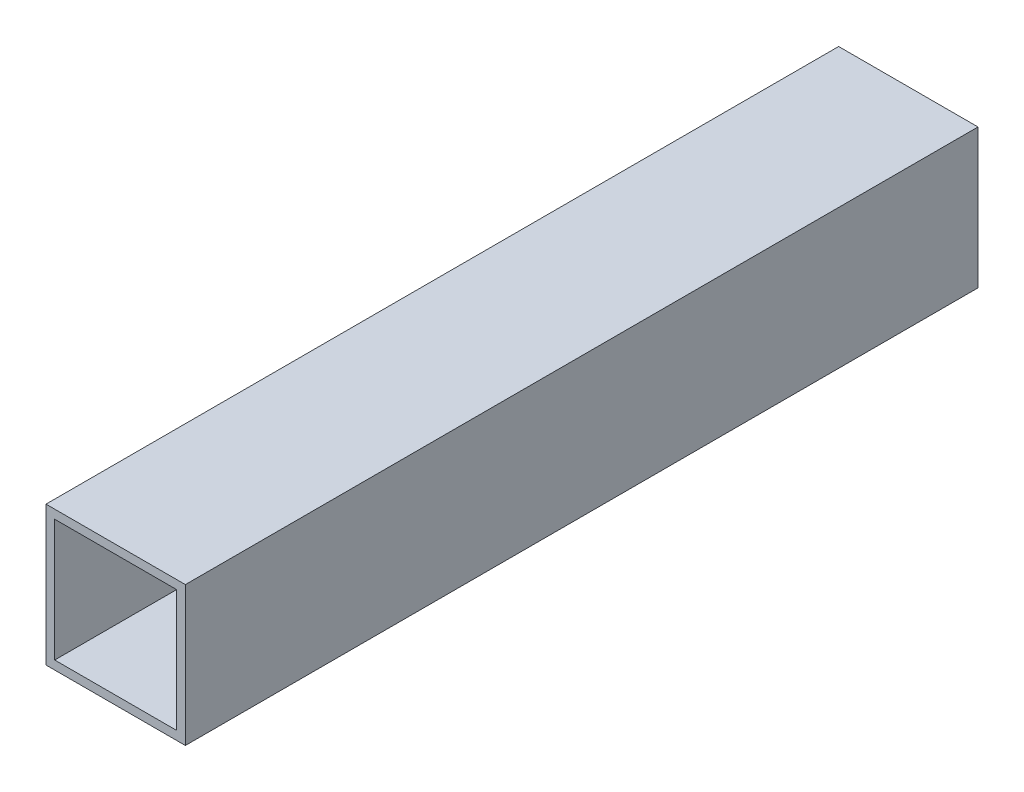
from build123d import *

# Parameters (mm, degrees)
SKETCH3_W                = 25.4
SKETCH3_H                = 25.4
SKETCH3_W_2              = 22.225
SKETCH3_H_2              = 22.225
BOSS_EXTRUDE1_DEPTH      = 76.2
BOSS_EXTRUDE1_DEPTH_BACK = 76.2
SKETCH4_W                = 25.4
SKETCH4_H                = 25.4
SKETCH4_W_2              = 22.225
SKETCH4_H_2              = 22.225
CUT_EXTRUDE1_DEPTH       = 7.9375


with BuildPart() as part:
    # Sketch3 → Boss-Extrude1 (new body, two sides)
    with BuildSketch(Plane.XY) as boss_extrude1_sk:
        Rectangle(SKETCH3_W, SKETCH3_H)
        Rectangle(SKETCH3_W_2, SKETCH3_H_2, mode=Mode.SUBTRACT)
    extrude(amount=BOSS_EXTRUDE1_DEPTH)
    extrude(boss_extrude1_sk.sketch, amount=-BOSS_EXTRUDE1_DEPTH_BACK)

    # Sketch4 → Cut-Extrude1 (cut)
    with BuildSketch(Plane(origin=(0, 0, -76.2), x_dir=(-1, 0, 0), z_dir=(0, 0, -1))):
        Rectangle(SKETCH4_W, SKETCH4_H)
        Rectangle(SKETCH4_W_2, SKETCH4_H_2, mode=Mode.SUBTRACT)
    extrude(amount=-CUT_EXTRUDE1_DEPTH, mode=Mode.SUBTRACT)


solid = part.part
